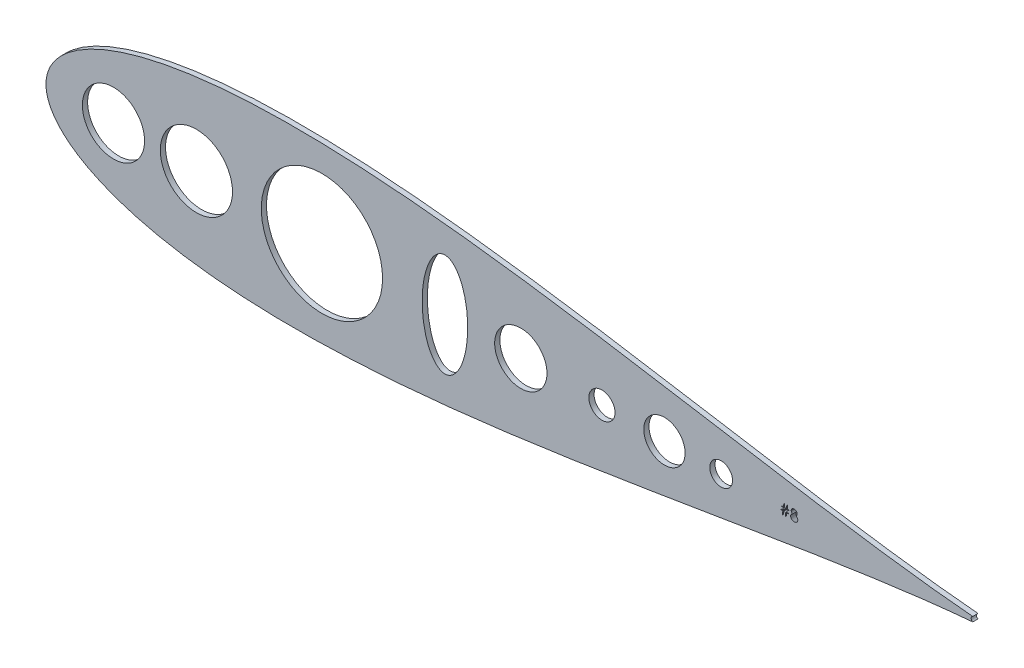
from build123d import *

# Parameters (mm, degrees)
SKETCH2_R           = 17.526
SKETCH2_R_2         = 15.091419844
SKETCH2_R_3         = 12.7
SKETCH2_R_4         = 6.35
SKETCH2_R_5         = 29.432567981
SKETCH2_R_6         = 10.034493983
SKETCH2_R_7         = 5.529942639
SKETCH2_RX          = 24.988140164
SKETCH2_RY          = 11.061872962
BOSS_EXTRUDE1_DEPTH = 2.54


with BuildPart() as part:
    # Sketch2 → Boss-Extrude1 (new body)
    with BuildSketch(Plane.XY):
        with BuildLine():
            ThreePointArc((783.748027282, 546.689618071), (782.966197225, 545.535409011), (783.745877654, 544.379746767))
            add(Edge.make_bspline(
                [(783.748027282, 546.689618071), (783.5679072, 546.704791601), (781.017695824, 546.920989194), (775.815627031, 547.401806194), (767.824442049, 548.233099782), (758.964407937, 549.253177681), (749.268830674, 550.468155033), (738.782944311, 551.879268903), (727.552094775, 553.483355621), (715.624915702, 555.272129391), (703.052055694, 557.232865211), (689.886187678, 559.348056239), (676.181720902, 561.595855457), (661.994642772, 563.950348642), (647.382337444, 566.381817173), (632.403489668, 568.857270172), (617.117988267, 571.340840566), (601.586875652, 573.79437303), (585.872314731, 576.177938239), (570.037586439, 578.450541631), (554.147082318, 580.570643534), (538.26632015, 582.496899569), (522.461954842, 584.188754873), (506.801788603, 585.607160248), (491.354764479, 586.715141789), (476.190965002, 587.478492275), (461.381596954, 587.866414769), (446.998967137, 587.852012852), (433.116506703, 587.412439936), (419.808772295, 586.530485394), (407.151662702, 585.19336002), (395.222539054, 583.395036538), (384.100947944, 581.134884118), (373.869161507, 578.420465653), (364.613679475, 575.267689688), (356.426834302, 571.704647988), (349.40804526, 567.778523156), (343.66216988, 563.56898785), (339.285962149, 559.213531514), (336.323199566, 554.942441412), (334.671080582, 551.089068957), (334.003923708, 547.997944391), (333.85197272, 545.534772964), (334.003923708, 543.071601536), (334.671080582, 539.98047697), (336.323199566, 536.127104515), (339.285962149, 531.856014414), (343.66216988, 527.500558077), (349.40804526, 523.291022771), (356.426834302, 519.36489794), (364.613679475, 515.801856239), (373.869161507, 512.649080275), (384.100947944, 509.93466181), (395.222539054, 507.674509389), (407.151662702, 505.876185907), (419.808772295, 504.539060533), (433.116506703, 503.657105991), (446.998967137, 503.217533075), (461.381596954, 503.203131158), (476.190965002, 503.591053652), (491.354764479, 504.354404138), (506.801788603, 505.46238568), (522.461954842, 506.880791054), (538.26632015, 508.572646358), (554.147082318, 510.498902393), (570.037586439, 512.619004296), (585.872314731, 514.891607688), (601.586875652, 517.275172897), (617.117988267, 519.728705362), (632.403489668, 522.212275755), (647.382337444, 524.687728754), (661.994642772, 527.119197285), (676.181720902, 529.47369047), (689.886187678, 531.721489688), (703.052055694, 533.836680716), (715.624915702, 535.797416536), (727.552094775, 537.586190307), (738.782944311, 539.190277025), (749.268830674, 540.601390894), (758.964407937, 541.816368246), (767.824442049, 542.836446145), (775.815627031, 543.667739733), (781.016983046, 544.148490853), (783.566474427, 544.364632859), (783.745877654, 544.379746767)],
                knots=[0.020717632, 0.020717632, 0.020717632, 0.020717632, 0.021270888, 0.028552555, 0.036780684, 0.045920102, 0.055931764, 0.066772884, 0.07839713, 0.090754827, 0.103793165, 0.117456432, 0.131686226, 0.146421738, 0.161599998, 0.177156133, 0.193023668, 0.209134786, 0.225420633, 0.241811602, 0.258237647, 0.274628557, 0.290914287, 0.307025229, 0.322892517, 0.338448342, 0.353626207, 0.368361232, 0.382590428, 0.396252961, 0.409290412, 0.42164701, 0.433269881, 0.444109249, 0.45411864, 0.463255055, 0.471479114, 0.478755289, 0.485052318, 0.490344026, 0.494609833, 0.497833231, 0.5, 0.502166769, 0.505390167, 0.509655974, 0.514947682, 0.521244711, 0.528520886, 0.536744945, 0.54588136, 0.555890751, 0.566730119, 0.57835299, 0.590709588, 0.603747039, 0.617409572, 0.631638768, 0.646373793, 0.661551658, 0.677107483, 0.692974771, 0.709085713, 0.725371443, 0.741762353, 0.758188398, 0.774579367, 0.790865214, 0.806976332, 0.822843867, 0.838400002, 0.853578262, 0.868313774, 0.882543568, 0.896206835, 0.909245173, 0.92160287, 0.933227116, 0.944068236, 0.954079898, 0.963219316, 0.971447445, 0.978729112, 0.979280167, 0.979280167, 0.979280167, 0.979280167], degree=3))
        make_face()
        with Locations((406.897680986, 545.534772967)):
            Circle(SKETCH2_R, mode=Mode.SUBTRACT)
        with Locations((366.646274072, 545.534772967)):
            Circle(SKETCH2_R_2, mode=Mode.SUBTRACT)
        with Locations((564.377680986, 545.534772967)):
            Circle(SKETCH2_R_3, mode=Mode.SUBTRACT)
        with Locations((603.747680986, 545.534772967)):
            Circle(SKETCH2_R_4, mode=Mode.SUBTRACT)
        with Locations((467.825509539, 545.534772967)):
            Circle(SKETCH2_R_5, mode=Mode.SUBTRACT)
        with Locations((634.083429255, 545.534772967)):
            Circle(SKETCH2_R_6, mode=Mode.SUBTRACT)
        with Locations((661.614358496, 545.534772967)):
            Circle(SKETCH2_R_7, mode=Mode.SUBTRACT)
        with Locations(Location((527.536771351, 545.534772967), (0, 0, -90))):
            Ellipse(SKETCH2_RX, SKETCH2_RY, mode=Mode.SUBTRACT)
        Polygon((694.376784929, 545.365298782), (694.376784929, 545.039657747), (693.405967628, 545.039657747), (693.142401917, 543.281196209), (692.748579804, 543.281196209), (693.012145505, 545.039657747), (691.973147115, 545.039657747), (691.709581404, 543.281196209), (691.315759291, 543.281196209), (691.579324992, 545.039657747), (690.729605442, 545.039657747), (690.729605442, 545.365298782), (691.628171153, 545.365298782), (691.804220829, 546.53760647), (690.859861854, 546.53760647), (690.859861854, 546.863247496), (691.853066979, 546.863247496), (692.097297753, 548.491452621), (692.490102241, 548.491452621), (692.245871467, 546.863247496), (693.285887492, 546.863247496), (693.530118266, 548.491452621), (693.922922753, 548.491452621), (693.678691979, 546.863247496), (694.507041341, 546.863247496), (694.507041341, 546.53760647), (693.629845829, 546.53760647), (693.454813778, 545.365298782), align=None, mode=Mode.SUBTRACT)
        Polygon((697.823491665, 546.111220247), (697.947642304, 546.04507442), (698.062634291, 545.976893332), (698.168467628, 545.905659357), (698.266159929, 545.833407747), (698.355711216, 545.75810327), (698.436103841, 545.679745895), (698.507337816, 545.600370895), (698.570430766, 545.517943008), (698.625382691, 545.43347987), (698.673211216, 545.345963845), (698.713916341, 545.255394933), (698.746480442, 545.16279077), (698.772938778, 545.066116084), (698.79125609, 544.967406146), (698.801432366, 544.865643332), (698.805502879, 544.760827621), (698.799397115, 544.614289159), (698.781079804, 544.471821209), (698.75156859, 544.333423782), (698.709845829, 544.200114483), (698.654893904, 544.069858071), (698.588748078, 543.945707433), (698.511408329, 543.824609671), (698.420839417, 543.708600058), (698.296688778, 543.578343646), (698.160326603, 543.464369295), (698.010735253, 543.368712234), (697.847914741, 543.29035487), (697.672882691, 543.229297171), (697.485639103, 543.185539159), (697.285166341, 543.160098458), (697.072482052, 543.150939807), (696.867938778, 543.159080832), (696.675607052, 543.181468646), (696.495486854, 543.220138521), (696.329613454, 543.273055184), (696.174933967, 543.342253908), (696.034501278, 543.426717046), (695.906280128, 543.525426983), (695.790270505, 543.64041897), (695.687490065, 543.764569609), (695.598956404, 543.891773134), (695.524669552, 544.022029546), (695.462594228, 544.155338845), (695.414765703, 544.291701021), (695.381183967, 544.431116084), (695.360831404, 544.573584033), (695.353708005, 544.71910487), (695.357778527, 544.825955832), (695.368972429, 544.929753908), (695.387289741, 545.030499096), (695.412730442, 545.129209033), (695.446312178, 545.224866084), (695.487017304, 545.317470247), (695.534845829, 545.408039159), (695.589797753, 545.495555184), (695.653908329, 545.581035958), (695.726159929, 545.663463845), (695.808587816, 545.74385647), (695.900174354, 545.822213845), (695.999901917, 545.898535958), (696.109805766, 545.971805184), (696.22785064, 546.043039159), (696.356071791, 546.111220247), (696.182057366, 546.211965445), (696.031448392, 546.324922171), (695.904244866, 546.448055184), (695.799429165, 546.583399734), (695.718018904, 546.72688532), (695.661031728, 546.875459033), (695.625414741, 547.029120895), (695.614220829, 547.187870895), (695.626432366, 547.349673782), (695.663066979, 547.509441408), (695.725142304, 547.668191408), (695.810623078, 547.823888521), (695.918491665, 547.971444609), (696.044677565, 548.101701021), (696.189180766, 548.215675383), (696.353018904, 548.313367684), (696.530086216, 548.391725058), (696.714276917, 548.446676983), (696.904573392, 548.480258709), (697.103010892, 548.491452621), (697.296360253, 548.480258709), (697.48156859, 548.446676983), (697.659653527, 548.389689807), (697.830615065, 548.311332433), (697.989365065, 548.213640121), (698.128780128, 548.098648134), (698.250895505, 547.968391722), (698.35469359, 547.82185327), (698.438139103, 547.666156146), (698.49716154, 547.505370895), (698.532778527, 547.341532747), (698.544990065, 547.173624096), (698.533796153, 547.008768332), (698.500214417, 546.853071209), (698.443227241, 546.706532747), (698.364869866, 546.569152945), (698.263107052, 546.440931795), (698.13997404, 546.32288692), (697.992417942, 546.211965445), align=None, mode=Mode.SUBTRACT)
    extrude(amount=BOSS_EXTRUDE1_DEPTH)


solid = part.part
